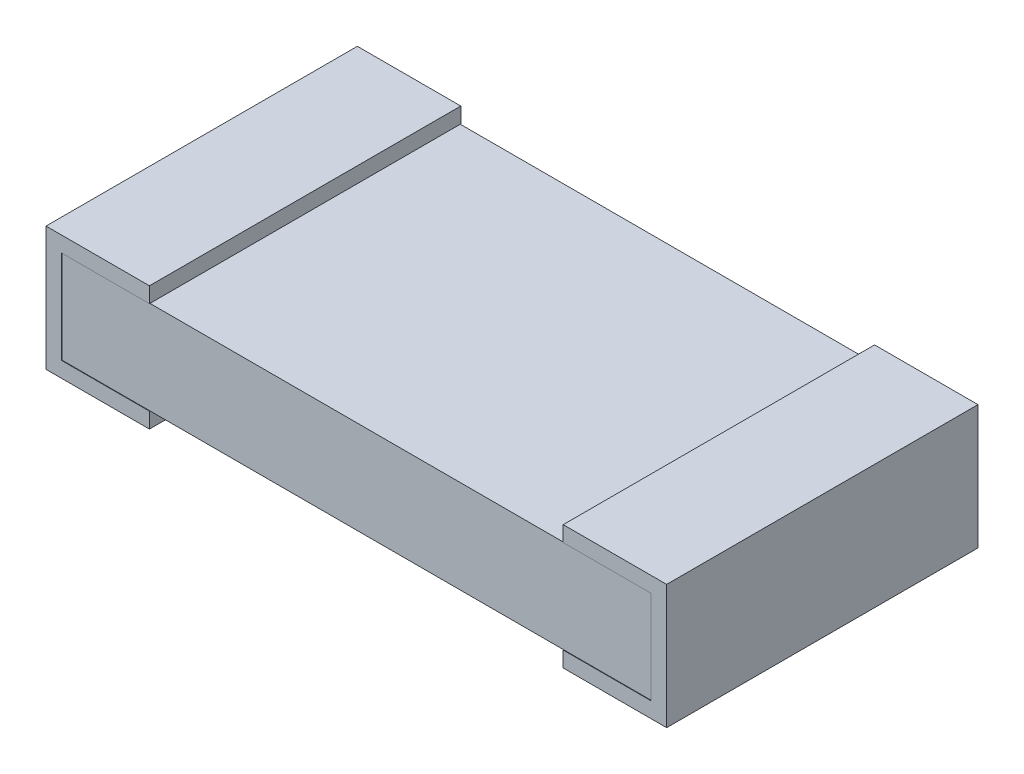
from build123d import *

# Parameters (mm, degrees)
SKETCH1_W           = 2.8956
SKETCH1_H           = 0.4572
BASE_EXTRUDE_DEPTH  = 0.762
BOSS_EXTRUDE1_DEPTH = 1.52908


with BuildPart() as part:
    # Sketch1 → Base-Extrude (new body, symmetric)
    with BuildSketch(Plane.XY):
        with Locations((1.524, 0.3048)):
            Rectangle(SKETCH1_W, SKETCH1_H)
    extrude(amount=BASE_EXTRUDE_DEPTH, both=True)

    # Sketch2 → Boss-Extrude1 (add)
    with BuildSketch(Plane(origin=(0, 0, -0.76454), x_dir=(-1, 0, 0), z_dir=(0, 0, -1))):
        Polygon((0, 0), (-0.508, 0), (-0.508, 0.0762), (-0.0762, 0.0762), (-0.0762, 0.5334), (-0.508, 0.5334), (-0.508, 0.6096), (0, 0.6096), align=None)
    boss_extrude1 = extrude(amount=-BOSS_EXTRUDE1_DEPTH)

    # Mirror1: Boss-Extrude1 across plane
    add(boss_extrude1.mirror(Plane(origin=(1.524, 0, 0), x_dir=(0, 0, 1), z_dir=(1, 0, 0))))


solid = part.part
